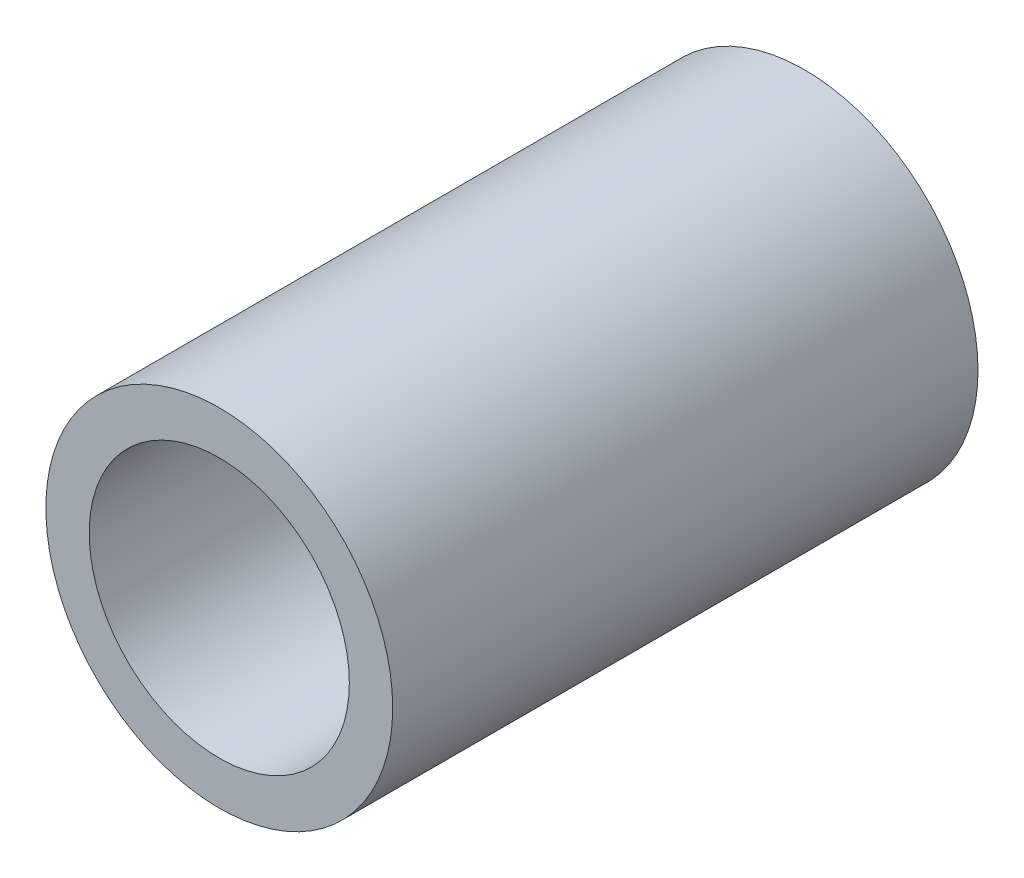
from build123d import *

# Parameters (mm, degrees)
SKETCH1_R           = 4.233333333
SKETCH1_R_2         = 3.175
BOSS_EXTRUDE1_DEPTH = 14.2875


with BuildPart() as part:
    # Sketch1 → Boss-Extrude1 (new body)
    with BuildSketch(Plane.XY):
        Circle(SKETCH1_R)
        Circle(SKETCH1_R_2, mode=Mode.SUBTRACT)
    extrude(amount=BOSS_EXTRUDE1_DEPTH)


solid = part.part
